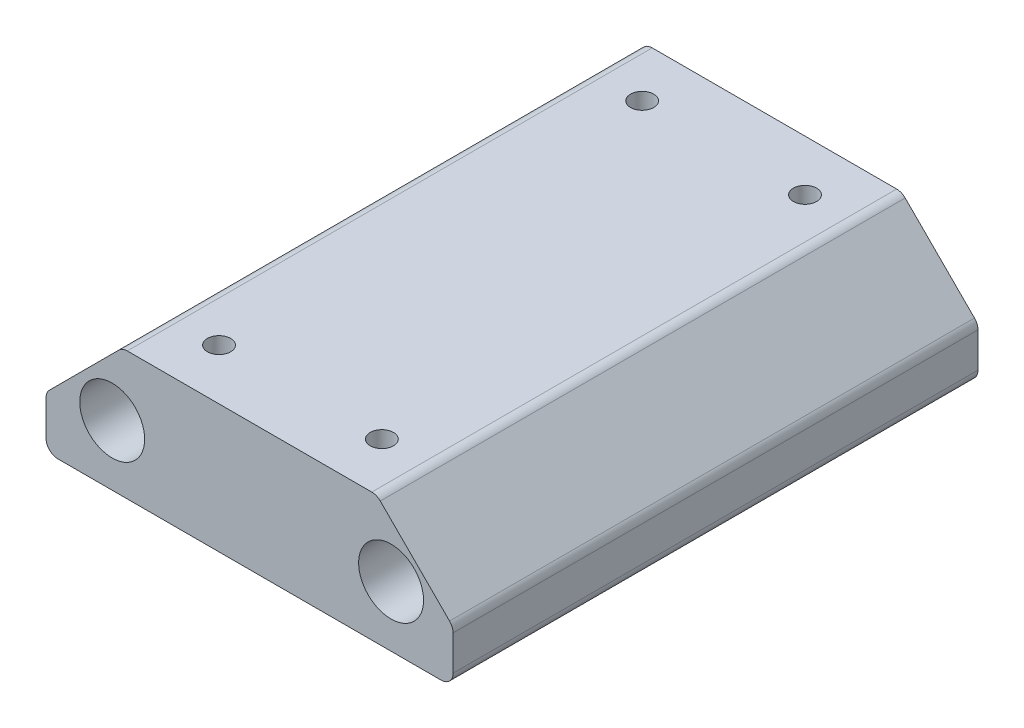
from build123d import *

# Parameters (mm, degrees)
SKETCH1_W           = 50.8
SKETCH1_H           = 16
SKETCH1_R           = 4.05
BOSS_EXTRUDE1_DEPTH = 65.5
FILLET1_R           = 1.5
CHAMFER1_SIZE       = 9.525
FILLET2_R           = 1.5
SKETCH3_R           = 1.45
CUT_EXTRUDE1_DEPTH  = 17


with BuildPart() as part:
    # Sketch1 → Boss-Extrude1 (new body)
    with BuildSketch(Plane.XY):
        with Locations((-0.262087977, -148.149956673)):
            Rectangle(SKETCH1_W, SKETCH1_H)
        with Locations((-17.4, -148.618426491)):
            Circle(SKETCH1_R, mode=Mode.SUBTRACT)
        with Locations((17.4, -148.618426491)):
            Circle(SKETCH1_R, mode=Mode.SUBTRACT)
    extrude(amount=BOSS_EXTRUDE1_DEPTH)

    # Fillet1
    fillet1_edges = [part.edges().sort_by_distance(p)[0] for p in [
        (25.137912023, -156.149956673, 32.75),
        (-25.662087977, -156.149956673, 32.75),
    ]]
    fillet(fillet1_edges, radius=FILLET1_R)

    # Chamfer1
    chamfer1_edges = [part.edges().sort_by_distance(p)[0] for p in [
        (-25.662087977, -140.149956673, 32.75),
        (25.137912023, -140.149956673, 32.75),
    ]]
    chamfer(chamfer1_edges, length=CHAMFER1_SIZE)

    # Fillet2
    fillet2_edges = [part.edges().sort_by_distance(p)[0] for p in [
        (-16.137087977, -140.149956673, 32.75),
        (15.612912023, -140.149956673, 32.75),
        (25.137912023, -149.674956673, 32.75),
        (-25.662087977, -149.674956673, 32.75),
    ]]
    fillet(fillet2_edges, radius=FILLET2_R)

    # Sketch3 → Cut-Extrude1 (cut, through all)
    with BuildSketch(Plane.XZ.offset(156.149956673)):
        with Locations((-10.422087977, 59.15)):
            Circle(SKETCH3_R)
        with Locations((9.897912023, 59.15)):
            Circle(SKETCH3_R)
        with Locations((-10.422087977, 6.35)):
            Circle(SKETCH3_R)
        with Locations((9.897912023, 6.35)):
            Circle(SKETCH3_R)
    extrude(amount=-CUT_EXTRUDE1_DEPTH, mode=Mode.SUBTRACT)


solid = part.part
